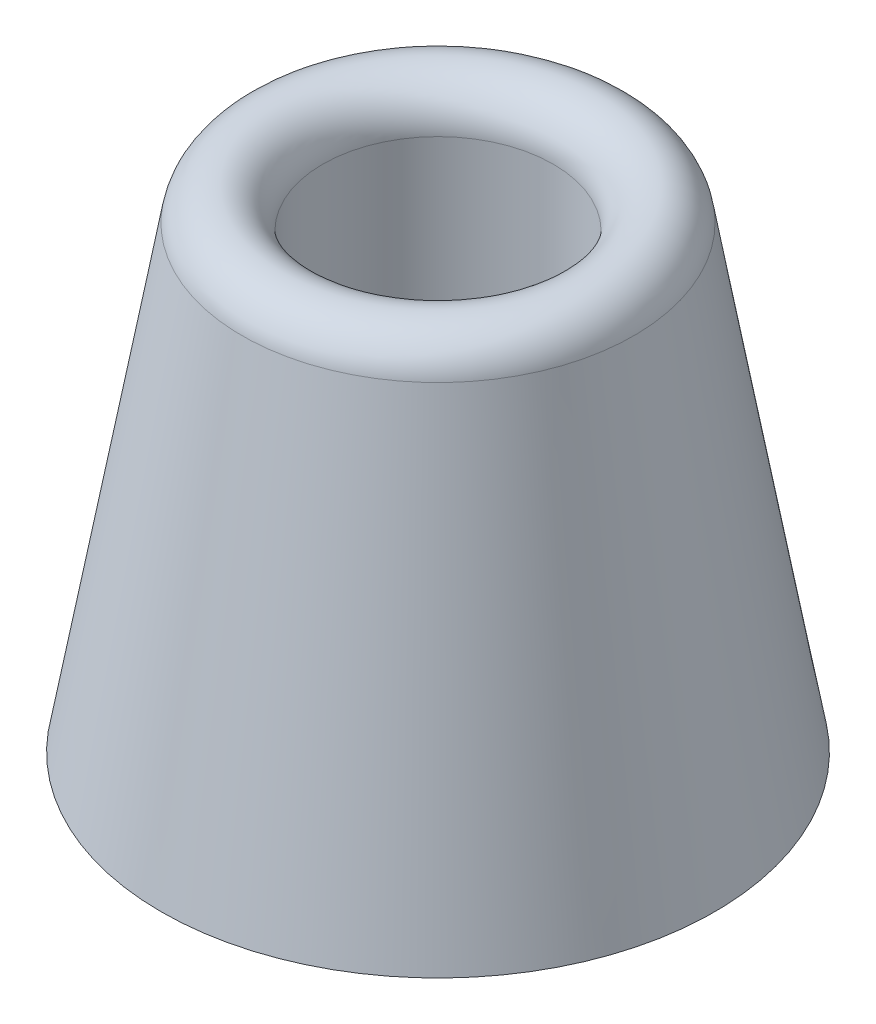
from build123d import *


with BuildPart() as part:
    # Sketch2 → Revolve1 (revolve)
    with BuildSketch(Plane.XY):
        with BuildLine():
            Line((14.2875, 0), (3.175, 0))
            Line((3.175, 0), (3.175, 13.890625))
            Line((3.175, 13.890625), (5.953125, 13.890625))
            Line((5.953125, 13.890625), (5.953125, 23.303501461))
            ThreePointArc((5.953125, 23.303501461), (7.866901652, 25.39202219), (10.114271555, 23.667554612))
            Line((10.114271555, 23.667554612), (14.2875, 0))
        make_face()
    revolve(axis=Axis((0, 0, 0), (0, 1, 0)))


solid = part.part
